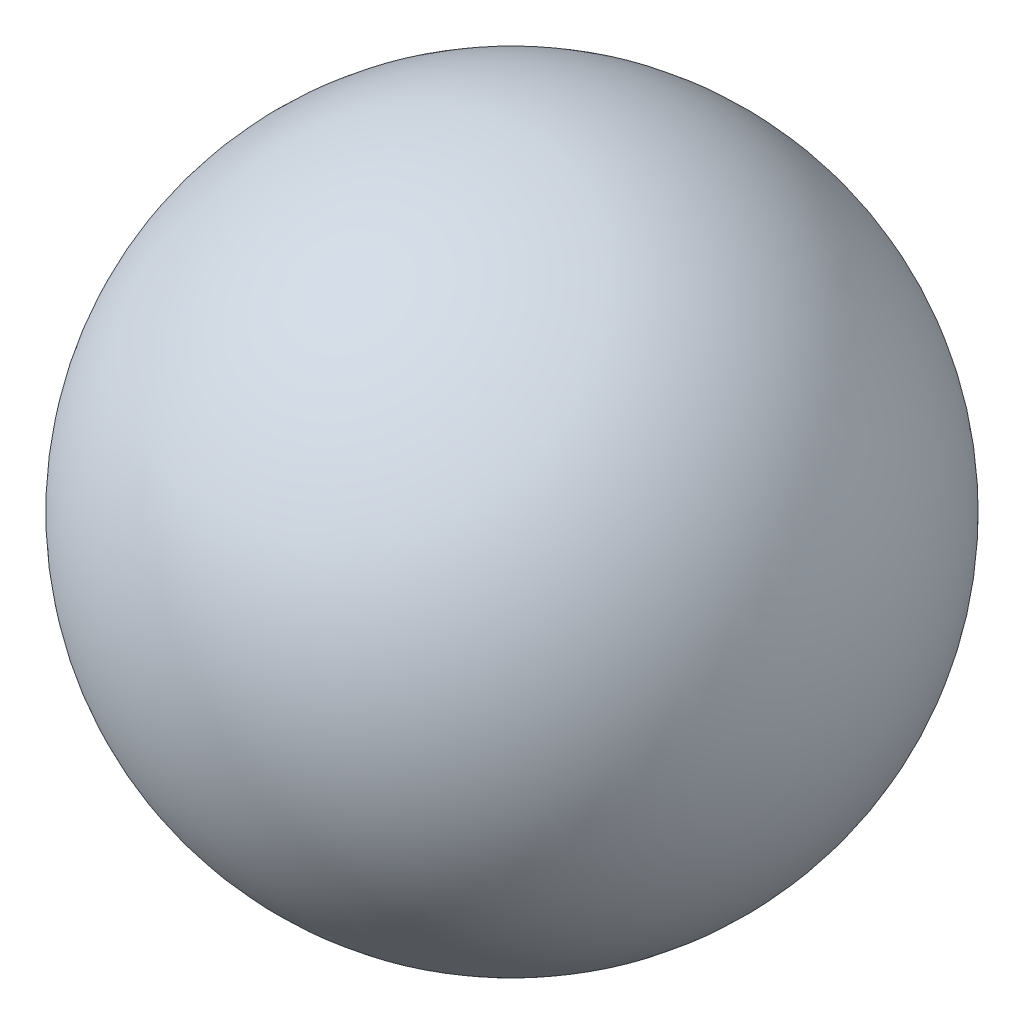
from build123d import *


with BuildPart() as part:
    # Sketch1 → Revolve1 (revolve)
    with BuildSketch(Plane.XY):
        with BuildLine():
            Line((0, -3.25), (0, 3.25))
            ThreePointArc((0, 3.25), (3.25, 0), (0, -3.25))
        make_face()
    revolve(axis=Axis((0, -3.25, 0), (0, 1, 0)))


solid = part.part
